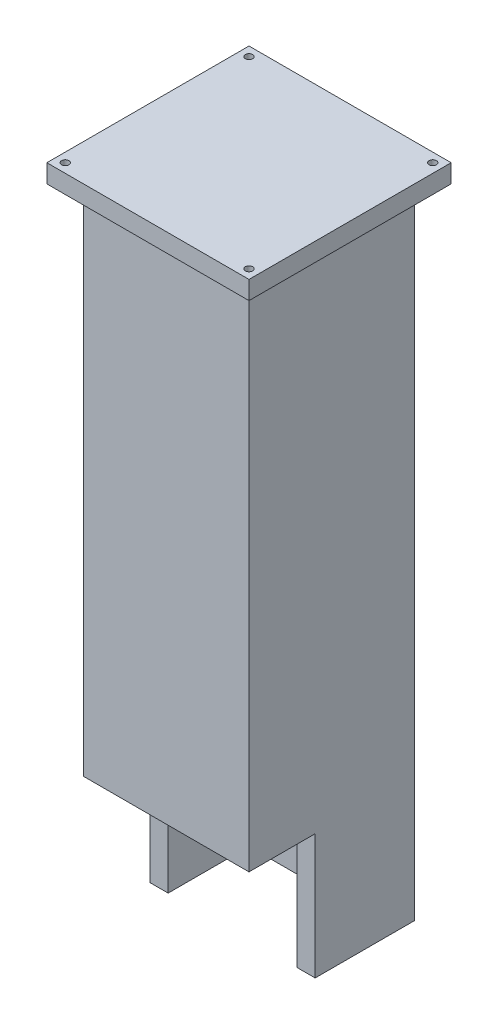
from build123d import *

# Parameters (mm, degrees)
CROQUIS1_W                 = 45
CROQUIS1_H                 = 45
SALIENTE_EXTRUIR1_DEPTH    = 300
CROQUIS4_W                 = 18
CROQUIS4_H                 = 34
CORTAR_EXTRUIR2_DEPTH      = 46
CROQUIS8_W                 = 35
CROQUIS8_H                 = 35
CORTAR_EXTRUIR3_DEPTH      = 301
CROQUIS9_W                 = 35
CROQUIS9_H                 = 21.174410022
CORTAR_EXTRUIR4_DEPTH      = 10
CROQUIS10_R                = 1
CORTAR_EXTRUIR5_DEPTH      = 10
CROQUIS11_W                = 45
CROQUIS11_H                = 26.387879272
CORTAR_EXTRUIR6_DEPTH      = 46
CROQUIS13_W                = 45
CROQUIS13_H                = 100
CORTAR_EXTRUIR9_DEPTH      = 23.5
CORTAR_EXTRUIR9_DEPTH_BACK = 23.5
CROQUIS14_W                = 55
CROQUIS14_H                = 55
CROQUIS14_R                = 1
SALIENTE_EXTRUIR3_DEPTH    = 5


with BuildPart() as part:
    # Croquis1 → Saliente-Extruir1 (new body)
    with BuildSketch(Plane(origin=(0, 0, 0), x_dir=(1, 0, 0), z_dir=(0, 1, 0))):
        Rectangle(CROQUIS1_W, CROQUIS1_H)
    extrude(amount=SALIENTE_EXTRUIR1_DEPTH)

    # Croquis4 → Cortar-Extruir2 (cut, through all)
    with BuildSketch(Plane.ZY.offset(22.5)):
        with Locations((13.5, 17)):
            Rectangle(CROQUIS4_W, CROQUIS4_H)
    extrude(amount=-CORTAR_EXTRUIR2_DEPTH, mode=Mode.SUBTRACT)

    # Croquis8 → Cortar-Extruir3 (cut, through all)
    with BuildSketch(Plane(origin=(0, 300, 0), x_dir=(1, 0, 0), z_dir=(0, 1, 0))):
        Rectangle(CROQUIS8_W, CROQUIS8_H)
    extrude(amount=-CORTAR_EXTRUIR3_DEPTH, mode=Mode.SUBTRACT)

    # Croquis9 → Cortar-Extruir4 (cut)
    with BuildSketch(Plane(origin=(0, 0, -22.5), x_dir=(-1, 0, 0), z_dir=(0, 0, -1))):
        with Locations((0, 260)):
            Rectangle(CROQUIS9_W, CROQUIS9_H)
    extrude(amount=-CORTAR_EXTRUIR4_DEPTH, mode=Mode.SUBTRACT)

    # Croquis10 → Cortar-Extruir5 (cut)
    with BuildSketch(Plane.XY.offset(22.5)):
        with Locations((0, 260)):
            Circle(CROQUIS10_R)
    extrude(amount=-CORTAR_EXTRUIR5_DEPTH, mode=Mode.SUBTRACT)

    # Croquis11 → Cortar-Extruir6 (cut, through all)
    with BuildSketch(Plane.XY.offset(22.5)):
        with Locations((0, 286.806060364)):
            Rectangle(CROQUIS11_W, CROQUIS11_H)
    extrude(amount=-CORTAR_EXTRUIR6_DEPTH, mode=Mode.SUBTRACT)

    # Croquis13 → Cortar-Extruir9 (cut, two sides)
    with BuildSketch(Plane(origin=(0, 0, 0), x_dir=(0, 0, -1), z_dir=(1, 0, 0))) as cortar_extruir9_sk:
        with Locations((0, 223.612120728)):
            Rectangle(CROQUIS13_W, CROQUIS13_H)
    extrude(amount=CORTAR_EXTRUIR9_DEPTH, mode=Mode.SUBTRACT)
    extrude(cortar_extruir9_sk.sketch, amount=-CORTAR_EXTRUIR9_DEPTH_BACK, mode=Mode.SUBTRACT)

    # Croquis14 → Saliente-Extruir3 (add)
    with BuildSketch(Plane(origin=(0, 173.612120728, 0), x_dir=(1, 0, 0), z_dir=(0, 1, 0))):
        Rectangle(CROQUIS14_W, CROQUIS14_H)
        with Locations((-25, 25)):
            Circle(CROQUIS14_R, mode=Mode.SUBTRACT)
        with Locations((25, -25)):
            Circle(CROQUIS14_R, mode=Mode.SUBTRACT)
        with Locations((25, 25)):
            Circle(CROQUIS14_R, mode=Mode.SUBTRACT)
        with Locations((-25, -25)):
            Circle(CROQUIS14_R, mode=Mode.SUBTRACT)
    extrude(amount=SALIENTE_EXTRUIR3_DEPTH)


solid = part.part
